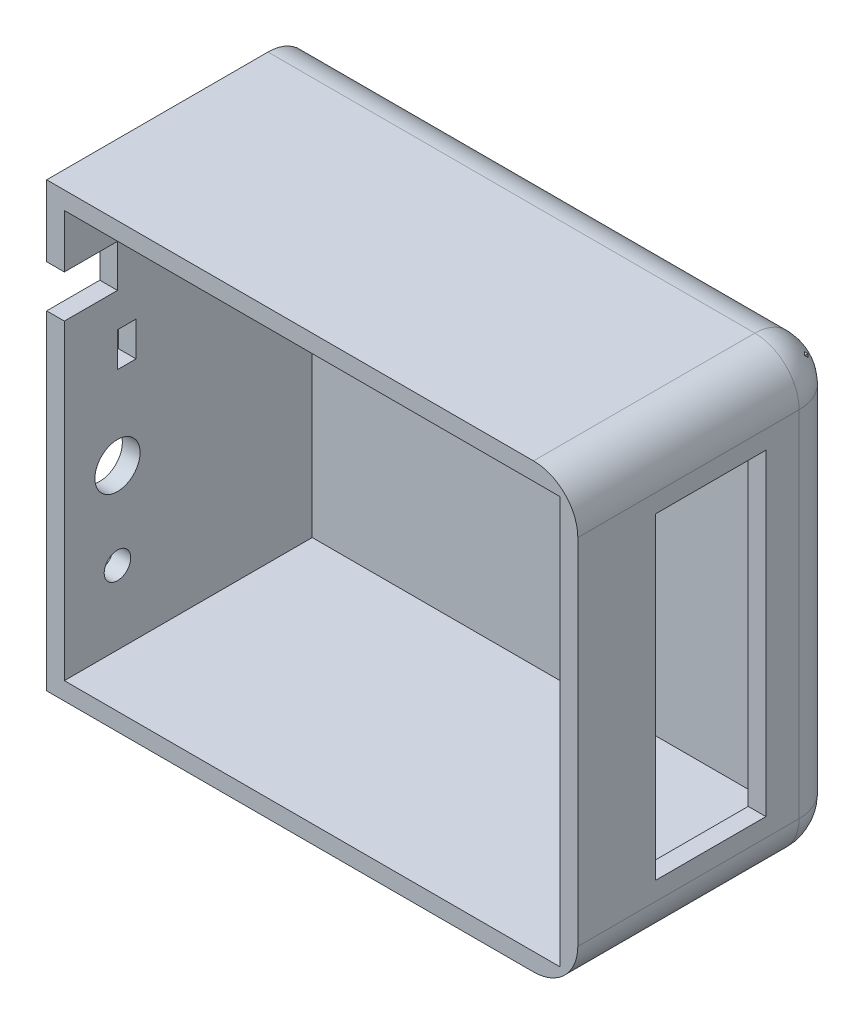
from build123d import *

# Parameters (mm, degrees)
ESBO_O1_W                  = 120
ESBO_O1_H                  = 100
RESSALTO_EXTRUS_O1_DEPTH   = 4
ESBO_O2_W                  = 4
ESBO_O2_H                  = 4
ESBO_O2_W_2                = 112
ESBO_O2_H_2                = 92
RESSALTO_EXTRUS_O2_DEPTH   = 60
CORTE_EXTRUS_O1_DEPTH      = 26
CORTE_EXTRUS_O1_DEPTH_BACK = 23
FILETE1_R                  = 10
FILETE2_R                  = 10
FILETE3_R                  = 10
CORTE_EXTRUS_O2_DEPTH      = 37
CORTE_EXTRUS_O2_DEPTH_BACK = 36
F_3DSKETCH3_R              = 5.1
F_3DSKETCH3_R_2            = 3
CORTE_EXTRUS_O3_DEPTH      = 28
CORTE_EXTRUS_O3_DEPTH_BACK = 18


with BuildPart() as part:
    # Esboço1 → Ressalto-extrusão1 (new body)
    with BuildSketch(Plane.XY):
        with Locations((60, 50)):
            Rectangle(ESBO_O1_W, ESBO_O1_H)
    extrude(amount=RESSALTO_EXTRUS_O1_DEPTH)

    # Esboço2 → Ressalto-extrusão2 (add)
    with BuildSketch(Plane.XY):
        with Locations((2, 98)):
            Rectangle(ESBO_O2_W, ESBO_O2_H)
        with Locations((118, 98)):
            Rectangle(ESBO_O2_W, ESBO_O2_H)
        with Locations((60, 98)):
            Rectangle(ESBO_O2_W_2, ESBO_O2_H)
        with Locations((118, 50)):
            Rectangle(ESBO_O2_W, ESBO_O2_H_2)
        with Locations((118, 2)):
            Rectangle(ESBO_O2_W, ESBO_O2_H)
        with Locations((60, 2)):
            Rectangle(ESBO_O2_W_2, ESBO_O2_H)
        with Locations((2, 2)):
            Rectangle(ESBO_O2_W, ESBO_O2_H)
        with Locations((2, 50)):
            Rectangle(ESBO_O2_W, ESBO_O2_H_2)
    extrude(amount=RESSALTO_EXTRUS_O2_DEPTH)

    # 3DSketch1 → Corte-extrusão1 (cut, two sides)
    with BuildSketch(Plane(origin=(120, 14.15, 17.5), x_dir=(0, 0.9442477948596217, 0.32923563279624185), z_dir=(1, 0, 0))) as corte_extrus_o1_sk:
        Polygon((0, 0), (8.23089082, 23.606194871), (75.933457711, 0), (67.702566891, -23.606194871), align=None)
    extrude(amount=CORTE_EXTRUS_O1_DEPTH, mode=Mode.SUBTRACT)
    extrude(corte_extrus_o1_sk.sketch, amount=-CORTE_EXTRUS_O1_DEPTH_BACK, mode=Mode.SUBTRACT)

    # Filete1
    filete1_edges = [part.edges().sort_by_distance(p)[0] for p in [
        (120, 50, 0),
    ]]
    fillet(filete1_edges, radius=FILETE1_R)

    # Filete2
    filete2_edges = [part.edges().sort_by_distance(p)[0] for p in [
        (55, 0, 0),
        (120, 0, 35),
        (117.071067812, 0, 2.928932188),
    ]]
    fillet(filete2_edges, radius=FILETE2_R)

    # Filete3
    filete3_edges = [part.edges().sort_by_distance(p)[0] for p in [
        (120, 100, 35),
        (55, 100, 0),
        (117.071067812, 100, 2.928932188),
    ]]
    fillet(filete3_edges, radius=FILETE3_R)

    # 3DSketch2 → Corte-extrusão2 (cut, two sides)
    with BuildSketch(Plane(origin=(0, 83.957923226, 60), x_dir=(0, -0.8401982536854657, -0.5422793509842448), z_dir=(1, 0, 0))) as corte_extrus_o2_sk:
        Polygon((0, 0), (6.507352212, 10.082379044), (14.573255447, 4.876497275), (8.065903235, -5.205881769), align=None)
        Polygon((21.042782001, 0.700946272), (23.320355275, 4.229778938), (29.873901653, 0), (27.596328379, -3.528832665), align=None)
    extrude(amount=CORTE_EXTRUS_O2_DEPTH, mode=Mode.SUBTRACT)
    extrude(corte_extrus_o2_sk.sketch, amount=-CORTE_EXTRUS_O2_DEPTH_BACK, mode=Mode.SUBTRACT)

    # 3DSketch3 → Corte-extrusão3 (cut, two sides)
    with BuildSketch(Plane(origin=(0, 40.094193259, 48), x_dir=(0, -1, 0), z_dir=(-1, 0, 0))) as corte_extrus_o3_sk:
        with Locations(Location((0, 0, 0), (0, 0, 180))):
            Circle(F_3DSKETCH3_R)
        with Locations(Location((19.533873925, 0, 0), (0, 0, 180))):
            Circle(F_3DSKETCH3_R_2)
    extrude(amount=CORTE_EXTRUS_O3_DEPTH, mode=Mode.SUBTRACT)
    extrude(corte_extrus_o3_sk.sketch, amount=-CORTE_EXTRUS_O3_DEPTH_BACK, mode=Mode.SUBTRACT)


solid = part.part
